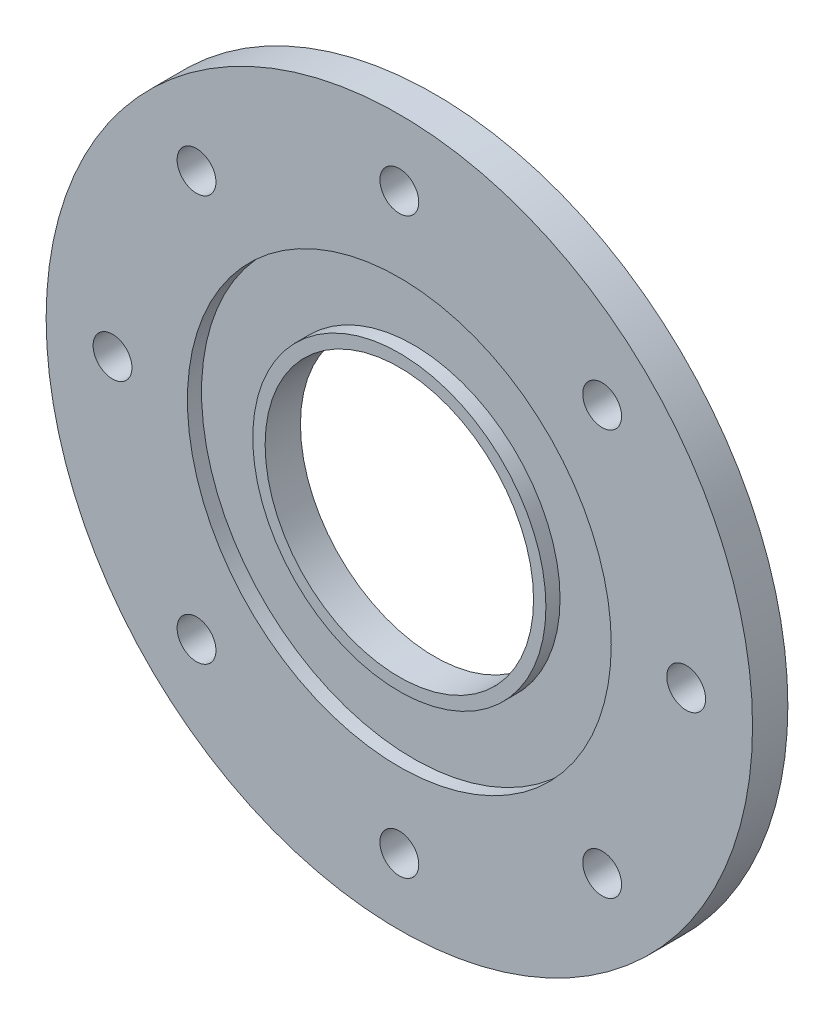
from build123d import *

# Parameters (mm, degrees)
CROQUIS1_R              = 50
CROQUIS1_R_2            = 19
SALIENTE_EXTRUIR1_DEPTH = 5
CROQUIS4_R              = 30
CROQUIS4_R_2            = 20.75
CORTAR_EXTRUIR1_DEPTH   = 2
CROQUIS5_R              = 2.75
CORTAR_EXTRUIR2_DEPTH   = 5


with BuildPart() as part:
    # Croquis1 → Saliente-Extruir1 (new body)
    with BuildSketch(Plane.XY):
        Circle(CROQUIS1_R)
        Circle(CROQUIS1_R_2, mode=Mode.SUBTRACT)
    extrude(amount=SALIENTE_EXTRUIR1_DEPTH)

    # Croquis4 → Cortar-Extruir1 (cut)
    with BuildSketch(Plane.XY.offset(5)):
        Circle(CROQUIS4_R)
        Circle(CROQUIS4_R_2, mode=Mode.SUBTRACT)
    extrude(amount=-CORTAR_EXTRUIR1_DEPTH, mode=Mode.SUBTRACT)

    # Croquis5 → Cortar-Extruir2 (cut)
    with BuildSketch(Plane.XY.offset(5)):
        with Locations((40.602997929, 0)):
            Circle(CROQUIS5_R)
        with Locations((28.710655172, -28.710655172)):
            Circle(CROQUIS5_R)
        with Locations((0, -40.602997929)):
            Circle(CROQUIS5_R)
        with Locations((-28.710655172, -28.710655172)):
            Circle(CROQUIS5_R)
        with Locations((-40.602997929, 0)):
            Circle(CROQUIS5_R)
        with Locations((-28.710655172, 28.710655172)):
            Circle(CROQUIS5_R)
        with Locations((0, 40.602997929)):
            Circle(CROQUIS5_R)
        with Locations((28.710655172, 28.710655172)):
            Circle(CROQUIS5_R)
    extrude(amount=-CORTAR_EXTRUIR2_DEPTH, mode=Mode.SUBTRACT)


solid = part.part
